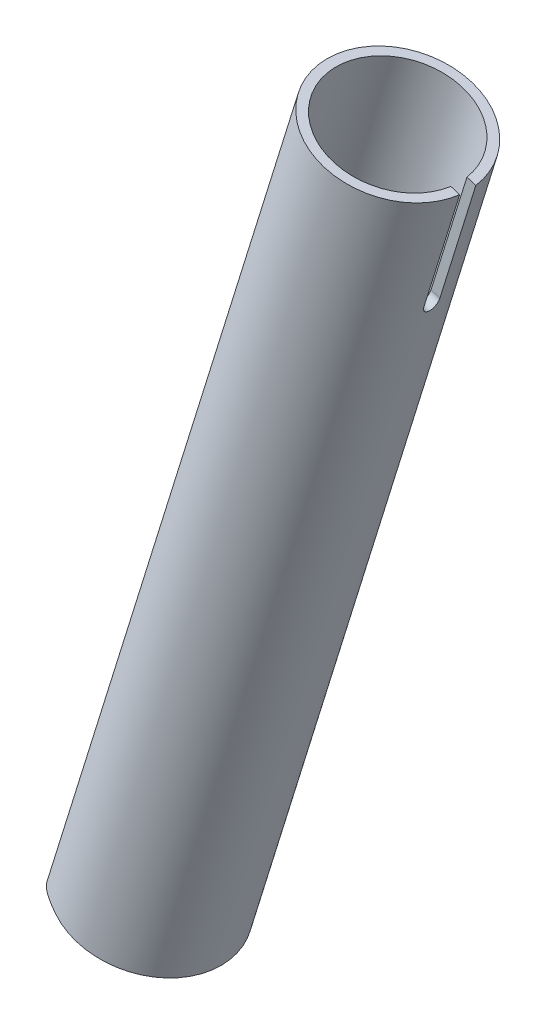
from build123d import *

# Parameters (mm, degrees)
ESQUISSE2_R                  = 16
ESQUISSE2_R_2                = 14
EXTRUSION5_DEPTH             = 213
ENL_V_MAT_EXTRU_1_DEPTH      = 17
ENL_V_MAT_EXTRU_1_DEPTH_BACK = 17
ENL_V_MAT_EXTRU_2_DEPTH      = 68.17581801


with BuildPart() as part:
    # Esquisse2 → Extrusion5 (new body)
    with BuildSketch(Plane(origin=(148.407000681, 477.467655605, 0), x_dir=(-0.954935311, 0.296814001, 0), z_dir=(0.296814001, 0.954935311, 0))):
        Circle(ESQUISSE2_R)
        Circle(ESQUISSE2_R_2, mode=Mode.SUBTRACT)
    extrude(amount=-EXTRUSION5_DEPTH)

    # Esquisse12 → Enlèv. mat.-Extru.1 (cut, two sides)
    with BuildSketch(Plane.XY) as enl_v_mat_extru_1_sk:
        with BuildLine():
            Line((67.680548401, 271.653443505), (76.584968442, 300.301502841))
            ThreePointArc((76.584968442, 300.301502841), (81.480701144, 306.1845671), (89.102461568, 306.88271594))
            Line((89.102461568, 306.88271594), (117.750520904, 297.978295899))
            ThreePointArc((117.750520904, 297.978295899), (132.458181552, 285.738964145), (134.20355365, 266.684563085))
            Line((134.20355365, 266.684563085), (125.29913361, 238.036503748))
            ThreePointArc((125.29913361, 238.036503748), (120.403400908, 232.153439489), (112.781640484, 231.45529065))
            Line((112.781640484, 231.45529065), (84.133581147, 240.359710691))
            ThreePointArc((84.133581147, 240.359710691), (69.4259205, 252.599042445), (67.680548401, 271.653443505))
        make_face()
    extrude(amount=ENL_V_MAT_EXTRU_1_DEPTH, mode=Mode.SUBTRACT)
    extrude(enl_v_mat_extru_1_sk.sketch, amount=-ENL_V_MAT_EXTRU_1_DEPTH_BACK, mode=Mode.SUBTRACT)

    # Esquisse13 → Enlèv. mat.-Extru.2 (cut, through all)
    with BuildSketch(Plane(origin=(0, 0, 0), x_dir=(0, 0, -1), z_dir=(0.954935311, -0.296814001, 0))):
        with BuildLine():
            Line((-1.75, 500), (1.75, 500))
            Line((1.75, 500), (1.75, 473.75))
            ThreePointArc((1.75, 473.75), (0, 472), (-1.75, 473.75))
            Line((-1.75, 473.75), (-1.75, 500))
        make_face()
    extrude(amount=ENL_V_MAT_EXTRU_2_DEPTH, mode=Mode.SUBTRACT)


solid = part.part
